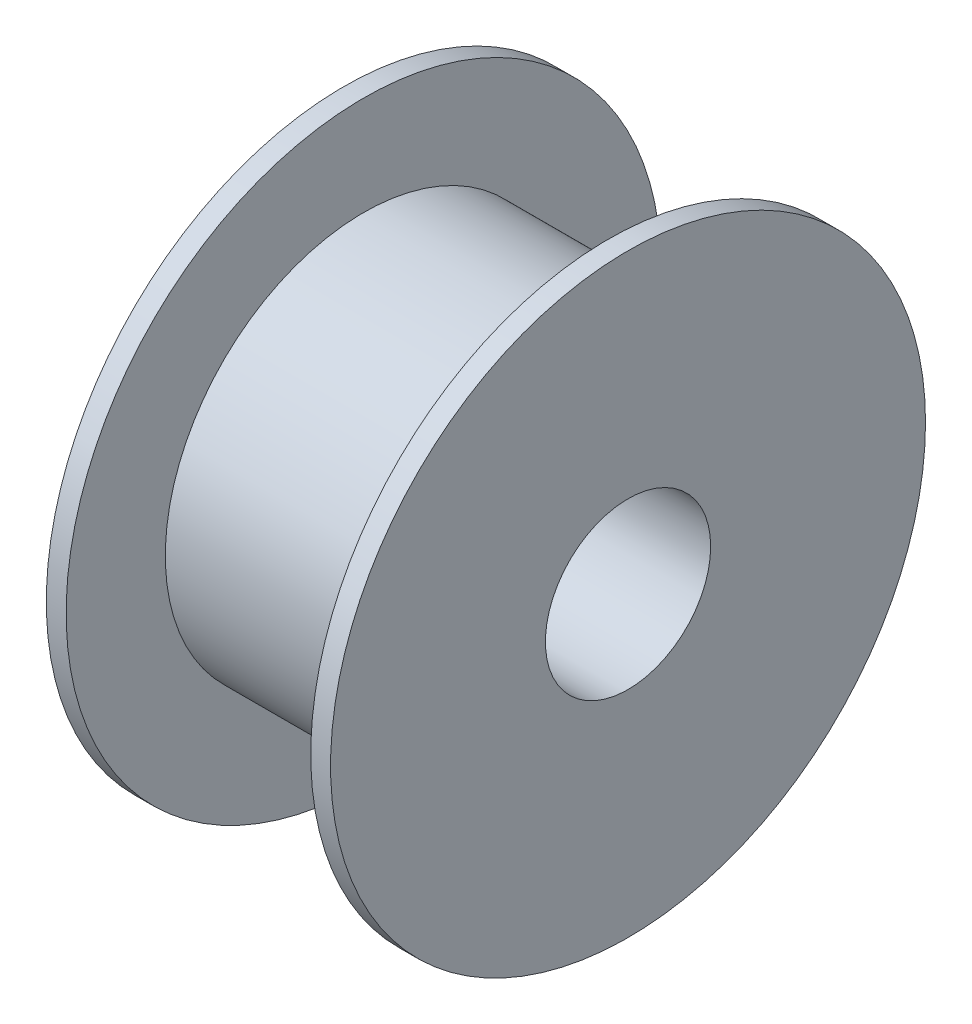
from build123d import *


with BuildPart() as part:
    # Sketch1 → Revolve1 (revolve)
    with BuildSketch(Plane.XY):
        Polygon((-0.6, 2.5), (8, 2.5), (8, 9), (7.4, 9), (7.4, 6), (0, 6), (0, 9), (-0.6, 9), align=None)
    revolve(axis=Axis((-0.6, 0, 0), (1, 0, 0)))


solid = part.part
